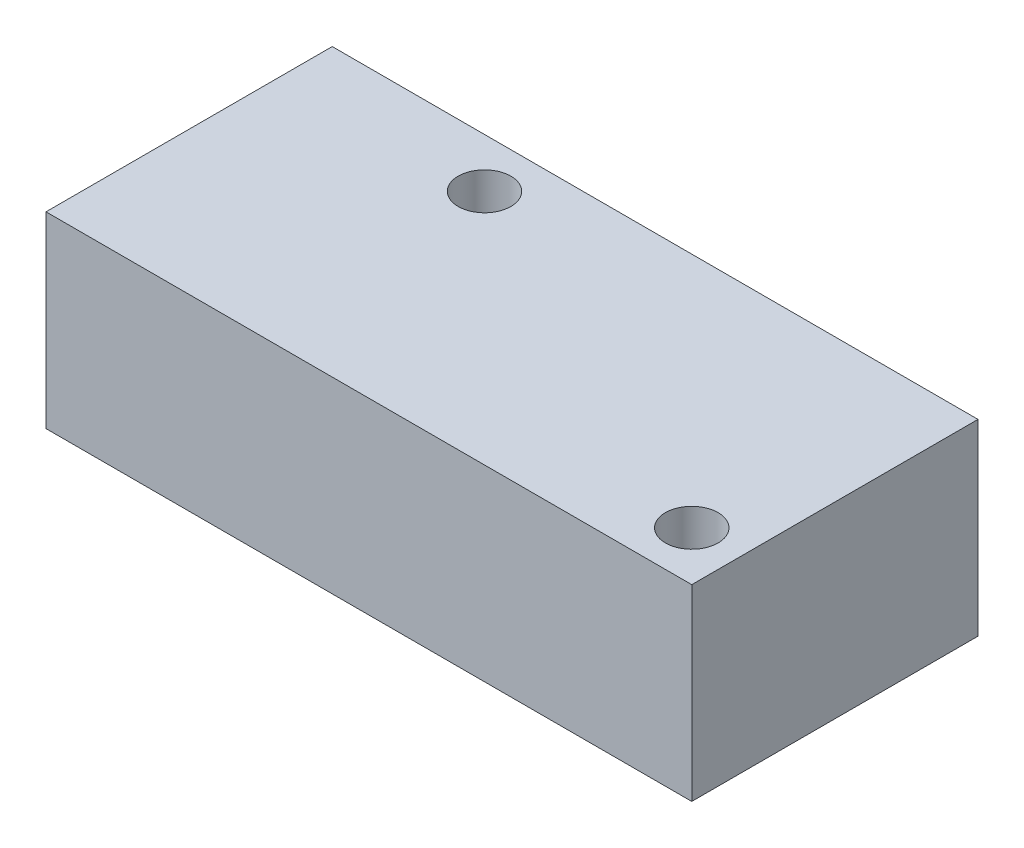
from build123d import *

# Parameters (mm, degrees)
SKETCH1_W           = 35.814
SKETCH1_H           = 15.875
SKETCH1_R           = 1.4605
BOSS_EXTRUDE1_DEPTH = 10.414


with BuildPart() as part:
    # Sketch1 → Boss-Extrude1 (new body)
    with BuildSketch(Plane(origin=(0, 0, 0), x_dir=(1, 0, 0), z_dir=(0, 1, 0))):
        with Locations((16.395769478, 7.9375)):
            Rectangle(SKETCH1_W, SKETCH1_H)
        with Locations((9.664769478, 13.1445)):
            Circle(SKETCH1_R, mode=Mode.SUBTRACT)
        with Locations((31.572269478, 2.7305)):
            Circle(SKETCH1_R, mode=Mode.SUBTRACT)
    extrude(amount=BOSS_EXTRUDE1_DEPTH)


solid = part.part
